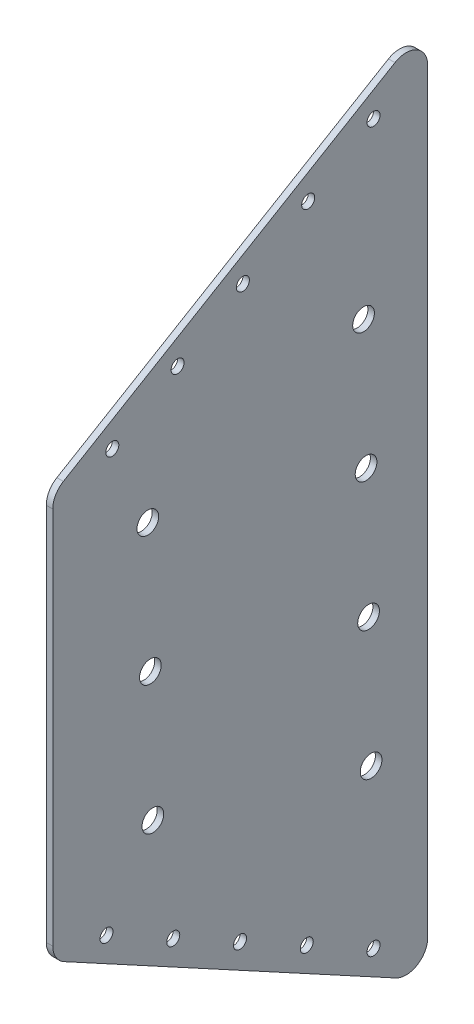
from build123d import *

# Parameters (mm, degrees)
BOSS_EXTRUDE1_DEPTH = 3
CUT_EXTRUDE1_REACH  = 5
SKETCH3_R           = 3
CUT_EXTRUDE2_REACH  = 5
SKETCH4_R           = 5
FILLET1_R           = 10


with BuildPart() as part:
    # Sketch1 → Boss-Extrude1 (new body)
    with BuildSketch(Plane(origin=(0, 0, 0), x_dir=(0, 0, -1), z_dir=(1, 0, 0))):
        Polygon((459.131022606, 411.733722484), (459.131022606, 597.849507888), (631.946459815, 700.452034157), (631.946459815, 317.945389168), align=None)
    extrude(amount=BOSS_EXTRUDE1_DEPTH)

    # Sketch3 → Cut-Extrude1 (cut, up to next)
    with BuildSketch(Plane(origin=(3, 0, 0), x_dir=(0, 0, -1), z_dir=(1, 0, 0)), mode=Mode.PRIVATE) as cut_extrude1_sk1:
        with Locations((516.660188982, 620.375565005)):
            Circle(SKETCH3_R)
    cut_extrude1_tool1 = extrude(cut_extrude1_sk1.sketch, amount=-CUT_EXTRUDE1_REACH, mode=Mode.PRIVATE) & part.part
    add(cut_extrude1_tool1.solids().sort_by_distance((3, 620.375565, -516.660189))[0], mode=Mode.SUBTRACT)
    # Sketch3 → Cut-Extrude1 (cut, up to next)
    with BuildSketch(Plane(origin=(3, 0, 0), x_dir=(0, 0, -1), z_dir=(1, 0, 0)), mode=Mode.PRIVATE) as cut_extrude1_sk2:
        with Locations((546.755612593, 638.243566507)):
            Circle(SKETCH3_R)
    cut_extrude1_tool2 = extrude(cut_extrude1_sk2.sketch, amount=-CUT_EXTRUDE1_REACH, mode=Mode.PRIVATE) & part.part
    add(cut_extrude1_tool2.solids().sort_by_distance((3, 638.243567, -546.755613))[0], mode=Mode.SUBTRACT)
    # Sketch3 → Cut-Extrude1 (cut, up to next)
    with BuildSketch(Plane(origin=(3, 0, 0), x_dir=(0, 0, -1), z_dir=(1, 0, 0)), mode=Mode.PRIVATE) as cut_extrude1_sk3:
        with Locations((576.851036204, 656.111568009)):
            Circle(SKETCH3_R)
    cut_extrude1_tool3 = extrude(cut_extrude1_sk3.sketch, amount=-CUT_EXTRUDE1_REACH, mode=Mode.PRIVATE) & part.part
    add(cut_extrude1_tool3.solids().sort_by_distance((3, 656.111568, -576.851036))[0], mode=Mode.SUBTRACT)
    # Sketch3 → Cut-Extrude1 (cut, up to next)
    with BuildSketch(Plane(origin=(3, 0, 0), x_dir=(0, 0, -1), z_dir=(1, 0, 0)), mode=Mode.PRIVATE) as cut_extrude1_sk4:
        with Locations((514.66108198, 392.974861297)):
            Circle(SKETCH3_R)
    cut_extrude1_tool4 = extrude(cut_extrude1_sk4.sketch, amount=-CUT_EXTRUDE1_REACH, mode=Mode.PRIVATE) & part.part
    add(cut_extrude1_tool4.solids().sort_by_distance((3, 392.974861, -514.661082))[0], mode=Mode.SUBTRACT)
    # Sketch3 → Cut-Extrude1 (cut, up to next)
    with BuildSketch(Plane(origin=(3, 0, 0), x_dir=(0, 0, -1), z_dir=(1, 0, 0)), mode=Mode.PRIVATE) as cut_extrude1_sk5:
        with Locations((545.422874592, 376.280188034)):
            Circle(SKETCH3_R)
    cut_extrude1_tool5 = extrude(cut_extrude1_sk5.sketch, amount=-CUT_EXTRUDE1_REACH, mode=Mode.PRIVATE) & part.part
    add(cut_extrude1_tool5.solids().sort_by_distance((3, 376.280188, -545.422875))[0], mode=Mode.SUBTRACT)
    # Sketch3 → Cut-Extrude1 (cut, up to next)
    with BuildSketch(Plane(origin=(3, 0, 0), x_dir=(0, 0, -1), z_dir=(1, 0, 0)), mode=Mode.PRIVATE) as cut_extrude1_sk6:
        with Locations((576.184667203, 359.585514772)):
            Circle(SKETCH3_R)
    cut_extrude1_tool6 = extrude(cut_extrude1_sk6.sketch, amount=-CUT_EXTRUDE1_REACH, mode=Mode.PRIVATE) & part.part
    add(cut_extrude1_tool6.solids().sort_by_distance((3, 359.585515, -576.184667))[0], mode=Mode.SUBTRACT)
    # Sketch3 → Cut-Extrude1 (cut, up to next)
    with BuildSketch(Plane(origin=(3, 0, 0), x_dir=(0, 0, -1), z_dir=(1, 0, 0)), mode=Mode.PRIVATE) as cut_extrude1_sk7:
        with Locations((486.564765371, 602.507563503)):
            Circle(SKETCH3_R)
    cut_extrude1_tool7 = extrude(cut_extrude1_sk7.sketch, amount=-CUT_EXTRUDE1_REACH, mode=Mode.PRIVATE) & part.part
    add(cut_extrude1_tool7.solids().sort_by_distance((3, 602.507564, -486.564765))[0], mode=Mode.SUBTRACT)
    # Sketch3 → Cut-Extrude1 (cut, up to next)
    with BuildSketch(Plane(origin=(3, 0, 0), x_dir=(0, 0, -1), z_dir=(1, 0, 0)), mode=Mode.PRIVATE) as cut_extrude1_sk8:
        with Locations((606.946459815, 673.979569511)):
            Circle(SKETCH3_R)
    cut_extrude1_tool8 = extrude(cut_extrude1_sk8.sketch, amount=-CUT_EXTRUDE1_REACH, mode=Mode.PRIVATE) & part.part
    add(cut_extrude1_tool8.solids().sort_by_distance((3, 673.97957, -606.94646))[0], mode=Mode.SUBTRACT)
    # Sketch3 → Cut-Extrude1 (cut, up to next)
    with BuildSketch(Plane(origin=(3, 0, 0), x_dir=(0, 0, -1), z_dir=(1, 0, 0)), mode=Mode.PRIVATE) as cut_extrude1_sk9:
        with Locations((483.899289369, 409.669534559)):
            Circle(SKETCH3_R)
    cut_extrude1_tool9 = extrude(cut_extrude1_sk9.sketch, amount=-CUT_EXTRUDE1_REACH, mode=Mode.PRIVATE) & part.part
    add(cut_extrude1_tool9.solids().sort_by_distance((3, 409.669535, -483.899289))[0], mode=Mode.SUBTRACT)
    # Sketch3 → Cut-Extrude1 (cut, up to next)
    with BuildSketch(Plane(origin=(3, 0, 0), x_dir=(0, 0, -1), z_dir=(1, 0, 0)), mode=Mode.PRIVATE) as cut_extrude1_sk10:
        with Locations((606.946459815, 342.89084151)):
            Circle(SKETCH3_R)
    cut_extrude1_tool10 = extrude(cut_extrude1_sk10.sketch, amount=-CUT_EXTRUDE1_REACH, mode=Mode.PRIVATE) & part.part
    add(cut_extrude1_tool10.solids().sort_by_distance((3, 342.890842, -606.94646))[0], mode=Mode.SUBTRACT)

    # Sketch4 → Cut-Extrude2 (cut, up to next)
    with BuildSketch(Plane(origin=(3, 0, 0), x_dir=(0, 0, -1), z_dir=(1, 0, 0)), mode=Mode.PRIVATE) as cut_extrude2_sk1:
        with Locations((602.36530116, 596.288363913)):
            Circle(SKETCH4_R)
    cut_extrude2_tool1 = extrude(cut_extrude2_sk1.sketch, amount=-CUT_EXTRUDE2_REACH, mode=Mode.PRIVATE) & part.part
    add(cut_extrude2_tool1.solids().sort_by_distance((3, 596.288364, -602.365301))[0], mode=Mode.SUBTRACT)
    # Sketch4 → Cut-Extrude2 (cut, up to next)
    with BuildSketch(Plane(origin=(3, 0, 0), x_dir=(0, 0, -1), z_dir=(1, 0, 0)), mode=Mode.PRIVATE) as cut_extrude2_sk2:
        with Locations((603.522472038, 536.299523655)):
            Circle(SKETCH4_R)
    cut_extrude2_tool2 = extrude(cut_extrude2_sk2.sketch, amount=-CUT_EXTRUDE2_REACH, mode=Mode.PRIVATE) & part.part
    add(cut_extrude2_tool2.solids().sort_by_distance((3, 536.299524, -603.522472))[0], mode=Mode.SUBTRACT)
    # Sketch4 → Cut-Extrude2 (cut, up to next)
    with BuildSketch(Plane(origin=(3, 0, 0), x_dir=(0, 0, -1), z_dir=(1, 0, 0)), mode=Mode.PRIVATE) as cut_extrude2_sk3:
        with Locations((604.679642916, 476.310683396)):
            Circle(SKETCH4_R)
    cut_extrude2_tool3 = extrude(cut_extrude2_sk3.sketch, amount=-CUT_EXTRUDE2_REACH, mode=Mode.PRIVATE) & part.part
    add(cut_extrude2_tool3.solids().sort_by_distance((3, 476.310683, -604.679643))[0], mode=Mode.SUBTRACT)
    # Sketch4 → Cut-Extrude2 (cut, up to next)
    with BuildSketch(Plane(origin=(3, 0, 0), x_dir=(0, 0, -1), z_dir=(1, 0, 0)), mode=Mode.PRIVATE) as cut_extrude2_sk4:
        with Locations((605.836813794, 416.321843138)):
            Circle(SKETCH4_R)
    cut_extrude2_tool4 = extrude(cut_extrude2_sk4.sketch, amount=-CUT_EXTRUDE2_REACH, mode=Mode.PRIVATE) & part.part
    add(cut_extrude2_tool4.solids().sort_by_distance((3, 416.321843, -605.836814))[0], mode=Mode.SUBTRACT)
    # Sketch4 → Cut-Extrude2 (cut, up to next)
    with BuildSketch(Plane(origin=(3, 0, 0), x_dir=(0, 0, -1), z_dir=(1, 0, 0)), mode=Mode.PRIVATE) as cut_extrude2_sk5:
        with Locations((502.953007582, 564.856704632)):
            Circle(SKETCH4_R)
    cut_extrude2_tool5 = extrude(cut_extrude2_sk5.sketch, amount=-CUT_EXTRUDE2_REACH, mode=Mode.PRIVATE) & part.part
    add(cut_extrude2_tool5.solids().sort_by_distance((3, 564.856705, -502.953008))[0], mode=Mode.SUBTRACT)
    # Sketch4 → Cut-Extrude2 (cut, up to next)
    with BuildSketch(Plane(origin=(3, 0, 0), x_dir=(0, 0, -1), z_dir=(1, 0, 0)), mode=Mode.PRIVATE) as cut_extrude2_sk6:
        with Locations((504.110178459, 504.867864374)):
            Circle(SKETCH4_R)
    cut_extrude2_tool6 = extrude(cut_extrude2_sk6.sketch, amount=-CUT_EXTRUDE2_REACH, mode=Mode.PRIVATE) & part.part
    add(cut_extrude2_tool6.solids().sort_by_distance((3, 504.867864, -504.110178))[0], mode=Mode.SUBTRACT)
    # Sketch4 → Cut-Extrude2 (cut, up to next)
    with BuildSketch(Plane(origin=(3, 0, 0), x_dir=(0, 0, -1), z_dir=(1, 0, 0)), mode=Mode.PRIVATE) as cut_extrude2_sk7:
        with Locations((505.267349337, 444.879024115)):
            Circle(SKETCH4_R)
    cut_extrude2_tool7 = extrude(cut_extrude2_sk7.sketch, amount=-CUT_EXTRUDE2_REACH, mode=Mode.PRIVATE) & part.part
    add(cut_extrude2_tool7.solids().sort_by_distance((3, 444.879024, -505.267349))[0], mode=Mode.SUBTRACT)

    # Fillet1
    fillet1_edges = [part.edges().sort_by_distance(p)[0] for p in [
        (1.5, 411.733722484, -459.131022606),
        (1.5, 597.849507888, -459.131022606),
        (1.5, 700.452034157, -631.946459815),
        (1.5, 317.945389168, -631.946459815),
    ]]
    fillet(fillet1_edges, radius=FILLET1_R)


solid = part.part
